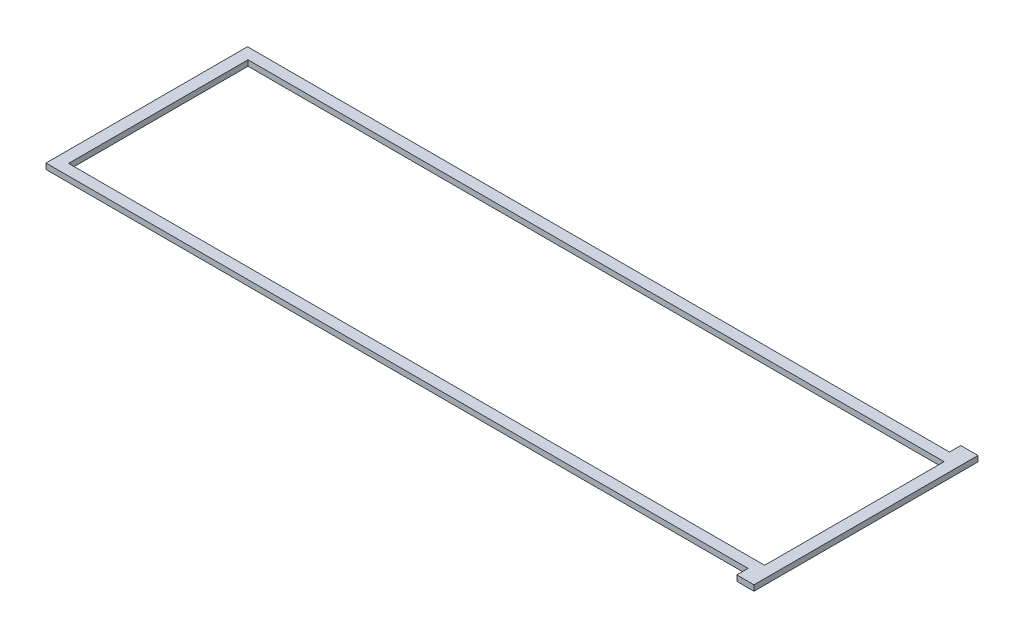
from build123d import *

# Parameters (mm, degrees)
SKETCH1_W           = 393.7
SKETCH1_H           = 101.6508
BOSS_EXTRUDE1_DEPTH = 3.175
SKETCH2_W           = 393.4968
SKETCH2_H           = 101.4476
BOSS_EXTRUDE2_DEPTH = 3.175


with BuildPart() as part:
    # Sketch1 → Boss-Extrude1 (new body)
    with BuildSketch(Plane(origin=(0, 0, 0), x_dir=(1, 0, 0), z_dir=(0, 1, 0))):
        Polygon((193.675, -56.848375), (193.675, -63.223775), (203.2, -63.223775), (203.2, 63.223775), (193.675, 63.223775), (193.675, 56.848375), (-203.2, 56.848375), (-203.2, -56.848375), align=None)
        with Locations((0, -0.0254)):
            Rectangle(SKETCH1_W, SKETCH1_H, mode=Mode.SUBTRACT)
    extrude(amount=BOSS_EXTRUDE1_DEPTH)

    # Sketch2 → Boss-Extrude2 (add)
    with BuildSketch(Plane(origin=(0, 3.175, 0), x_dir=(1, 0, 0), z_dir=(0, 1, 0))):
        Polygon((193.5734, -56.949975), (193.5734, -63.325375), (203.3016, -63.325375), (203.3016, 63.325375), (193.5734, 63.325375), (193.5734, 56.949975), (-203.3016, 56.949975), (-203.3016, -56.949975), align=None)
        with Locations((0, -0.0254)):
            Rectangle(SKETCH2_W, SKETCH2_H, mode=Mode.SUBTRACT)
    extrude(amount=-BOSS_EXTRUDE2_DEPTH)


solid = part.part
